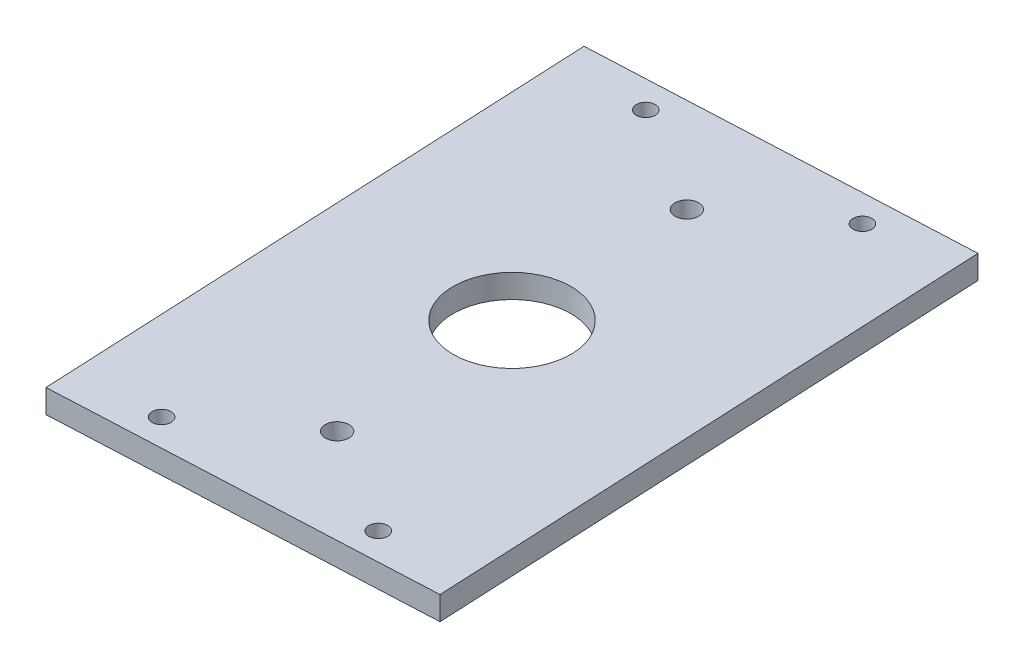
from build123d import *

# Parameters (mm, degrees)
SKETCH_1_W      = 80
SKETCH_1_H      = 120
SKETCH_1_R      = 2.5
SKETCH_1_R_2    = 2
SKETCH_1_R_3    = 12.5
EXTRUDE_1_DEPTH = 5


with BuildPart() as part:
    # 草图1 → 凸台-拉伸1 (new body)
    with BuildSketch(Plane(origin=(-72.587068572, 0, 457.027671738), x_dir=(0.998900163, 0, -0.046887783), z_dir=(0, 1, 0))):
        with Locations((93.936248853, 453.121569129)):
            Rectangle(SKETCH_1_W, SKETCH_1_H)
        with Locations((93.936248853, 492.121569129)):
            Circle(SKETCH_1_R, mode=Mode.SUBTRACT)
        with Locations((93.936248853, 414.121569129)):
            Circle(SKETCH_1_R, mode=Mode.SUBTRACT)
        with Locations((115.936248853, 507.121569129)):
            Circle(SKETCH_1_R_2, mode=Mode.SUBTRACT)
        with Locations((115.936248853, 399.121569129)):
            Circle(SKETCH_1_R_2, mode=Mode.SUBTRACT)
        with Locations((71.936248853, 507.121569129)):
            Circle(SKETCH_1_R_2, mode=Mode.SUBTRACT)
        with Locations((71.936248853, 399.121569129)):
            Circle(SKETCH_1_R_2, mode=Mode.SUBTRACT)
        with Locations((93.936248853, 453.121569129)):
            Circle(SKETCH_1_R_3, mode=Mode.SUBTRACT)
    extrude(amount=EXTRUDE_1_DEPTH)


solid = part.part
